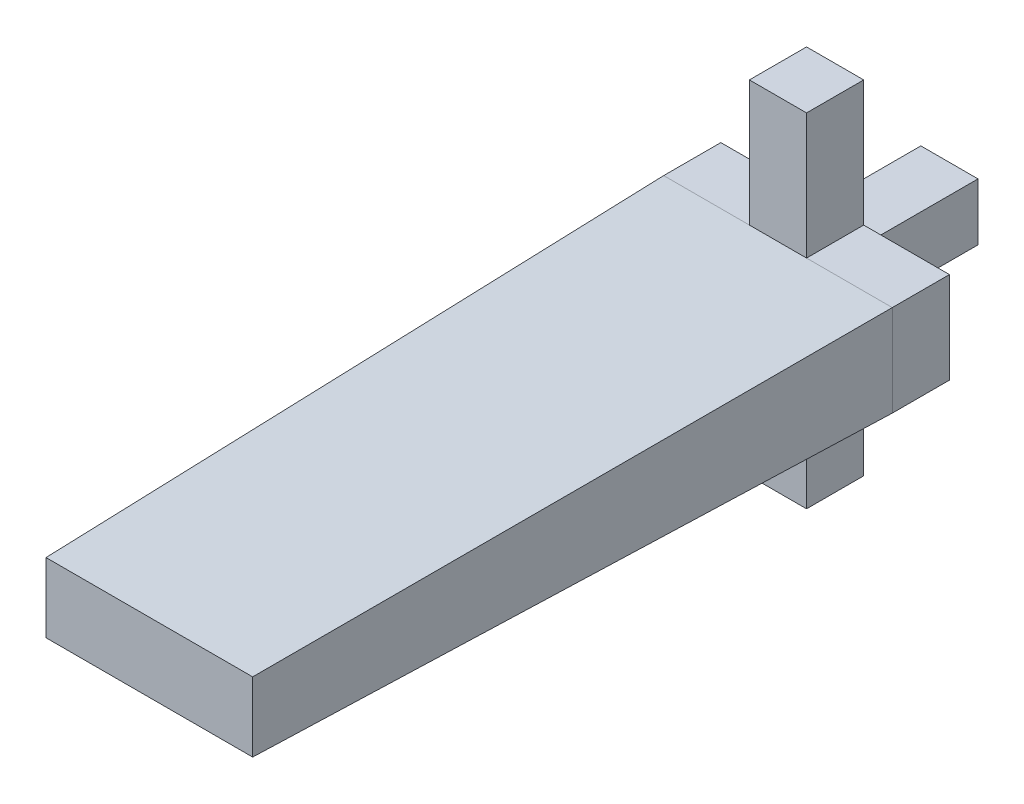
from build123d import *

# Parameters (mm, degrees)
SKETCH_1_W      = 20
SKETCH_1_H      = 8
EXTRUDE_1_DEPTH = 5
SKETCH_5_W      = 5
SKETCH_5_H      = 5
EXTRUDE_5_DEPTH = 10
SKETCH_8_W      = 20
SKETCH_8_H      = 8
EXTRUDE_6_DEPTH = 55
EXTRUDE_6_TAPER = 1
SKETCH_9_W      = 5
SKETCH_9_H      = 5
EXTRUDE_7_DEPTH = 11
SKETCH_10_W     = 5
SKETCH_10_H     = 5
EXTRUDE_8_DEPTH = 11


with BuildPart() as part:
    # ｽｹｯﾁ1 → ﾎﾞｽ - 押し出し1 (new body)
    with BuildSketch(Plane.XY):
        Rectangle(SKETCH_1_W, SKETCH_1_H)
    extrude(amount=EXTRUDE_1_DEPTH)

    # ｽｹｯﾁ5 → ﾎﾞｽ - 押し出し5 (add)
    with BuildSketch(Plane(origin=(0, 0, 0), x_dir=(-1, 0, 0), z_dir=(0, 0, -1))):
        Rectangle(SKETCH_5_W, SKETCH_5_H)
    extrude(amount=EXTRUDE_5_DEPTH)

    # ｽｹｯﾁ8 → ﾎﾞｽ - 押し出し6 (add)
    with BuildSketch(Plane.XY.offset(5)):
        Rectangle(SKETCH_8_W, SKETCH_8_H)
    extrude(amount=EXTRUDE_6_DEPTH, taper=EXTRUDE_6_TAPER)

    # ｽｹｯﾁ9 → ﾎﾞｽ - 押し出し7 (add)
    with BuildSketch(Plane(origin=(0, 4, 0), x_dir=(1, 0, 0), z_dir=(0, 1, 0))):
        with Locations((0, -2.5)):
            Rectangle(SKETCH_9_W, SKETCH_9_H)
    extrude(amount=EXTRUDE_7_DEPTH)

    # ｽｹｯﾁ10 → ﾎﾞｽ - 押し出し8 (add)
    with BuildSketch(Plane(origin=(0, -4, 0), x_dir=(-1, 0, 0), z_dir=(0, -1, 0))):
        with Locations((0, -2.5)):
            Rectangle(SKETCH_10_W, SKETCH_10_H)
    extrude(amount=EXTRUDE_8_DEPTH)


solid = part.part
